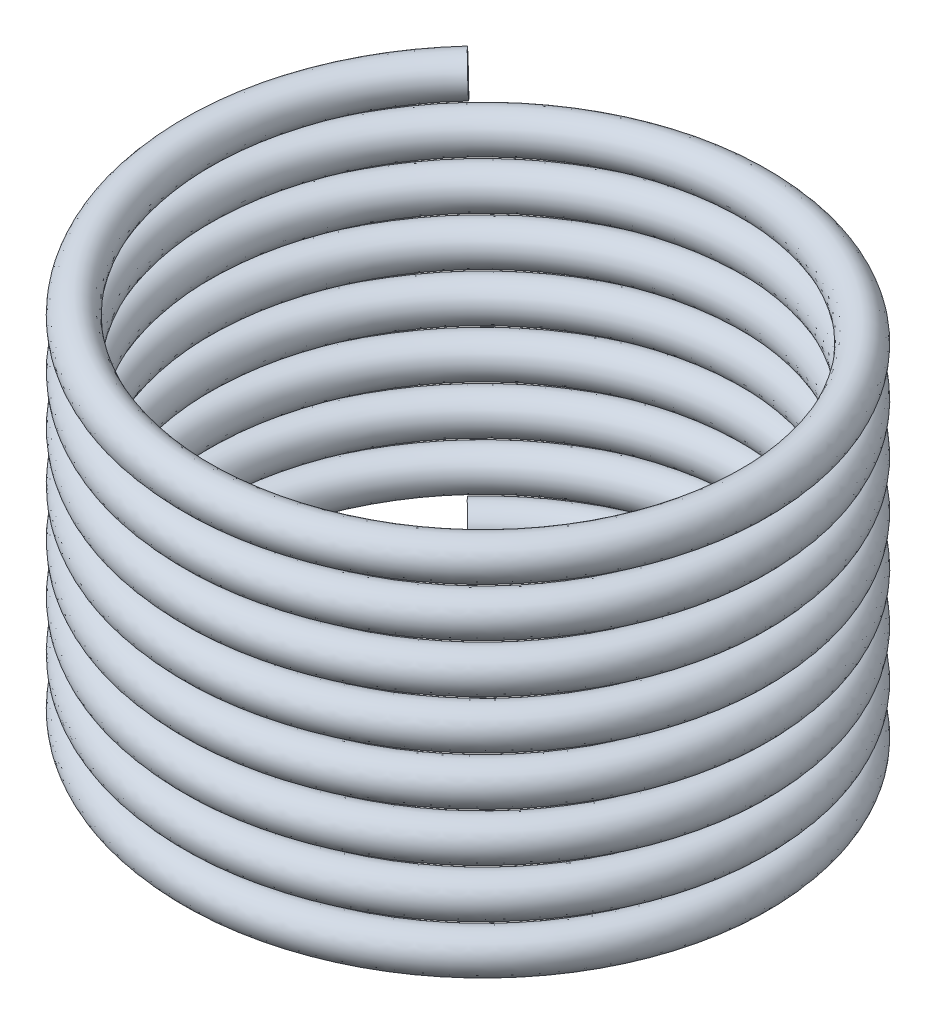
from build123d import *

# Parameters (mm, degrees)
AUSTRAGUNG2_PITCH       = 5
AUSTRAGUNG2_HEIGHT      = 40
AUSTRAGUNG2_RADIUS      = 28.622324187
AUSTRAGUNG2_START_ANGLE = -135
AUSTRAGUNG2_PROFILE_R   = 2


with BuildPart() as part:
    # Austragung2: sweep along a helix
    with BuildLine() as austragung2_path:
        add(Helix(AUSTRAGUNG2_PITCH, AUSTRAGUNG2_HEIGHT, AUSTRAGUNG2_RADIUS, center=(0, 0, 0), direction=(0, 1, 0), lefthand=True, mode=Mode.PRIVATE).rotate(Axis((0, 0, 0), (0, 1, 0)), AUSTRAGUNG2_START_ANGLE))
    # Austragung2 profile (on start of the path) → Austragung2 (sweep)
    with BuildSketch(Plane(origin=(-20.239039526, 0, -20.239039526), x_dir=(-0.707106781, 0, -0.707106781), z_dir=(0.706833648, 0.02779185, -0.706833648))):
        Circle(AUSTRAGUNG2_PROFILE_R)
    sweep(path=austragung2_path.line, is_frenet=True)


solid = part.part
